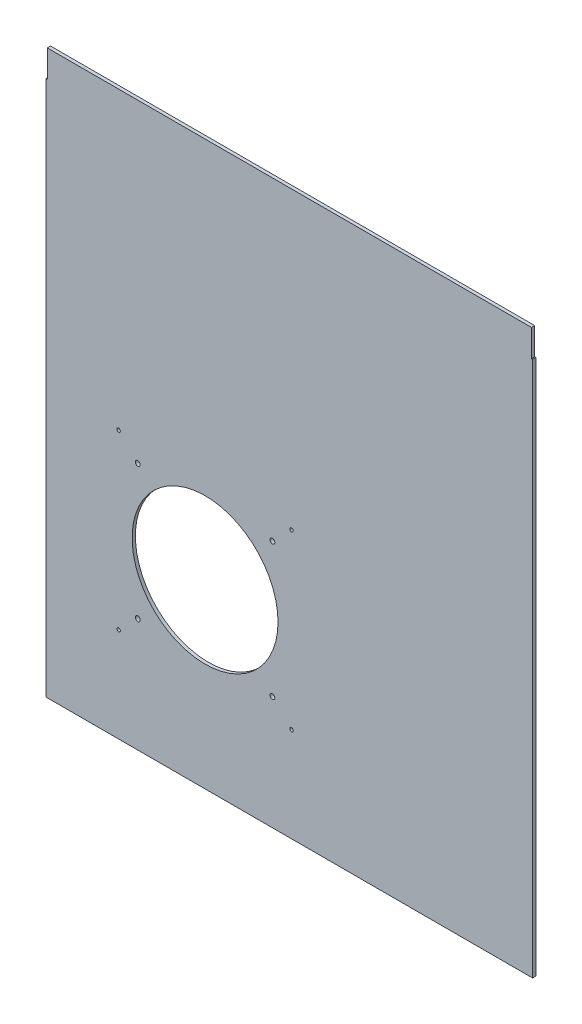
from build123d import *

# Parameters (mm, degrees)
SALIENTE_EXTRUIR1_DEPTH = 3
CROQUIS2_R              = 67.5
CROQUIS2_R_2            = 2.25
CROQUIS2_R_3            = 1.6
CORTAR_EXTRUIR1_DEPTH   = 3


with BuildPart() as part:
    # Croquis1 → Saliente-Extruir1 (new body)
    with BuildSketch(Plane.XY):
        Polygon((-261.838674033, 298.703267526), (-260.838674033, 298.703267526), (-260.838674033, 323.703267526), (187.161325967, 323.703267526), (187.161325967, 298.703267526), (188.161325967, 298.703267526), (188.161325967, -197.096732474), (-261.838674033, -197.096732474), align=None)
    extrude(amount=SALIENTE_EXTRUIR1_DEPTH)

    # Croquis2 → Cortar-Extruir1 (cut)
    with BuildSketch(Plane.XY.offset(3)):
        with Locations((-114.838674033, -29.596732474)):
            Circle(CROQUIS2_R)
        with Locations((-52.588674033, 32.653267526)):
            Circle(CROQUIS2_R_2)
        with Locations((-34.838674033, 50.403267526)):
            Circle(CROQUIS2_R_3)
        with Locations((-52.588674033, -91.846732474)):
            Circle(CROQUIS2_R_2)
        with Locations((-34.838674033, -109.596732474)):
            Circle(CROQUIS2_R_3)
        with Locations((-177.088674033, -91.846732474)):
            Circle(CROQUIS2_R_2)
        with Locations((-194.838674033, -109.596732474)):
            Circle(CROQUIS2_R_3)
        with Locations((-177.088674033, 32.653267526)):
            Circle(CROQUIS2_R_2)
        with Locations((-194.838674033, 50.403267526)):
            Circle(CROQUIS2_R_3)
    extrude(amount=-CORTAR_EXTRUIR1_DEPTH, mode=Mode.SUBTRACT)


solid = part.part
